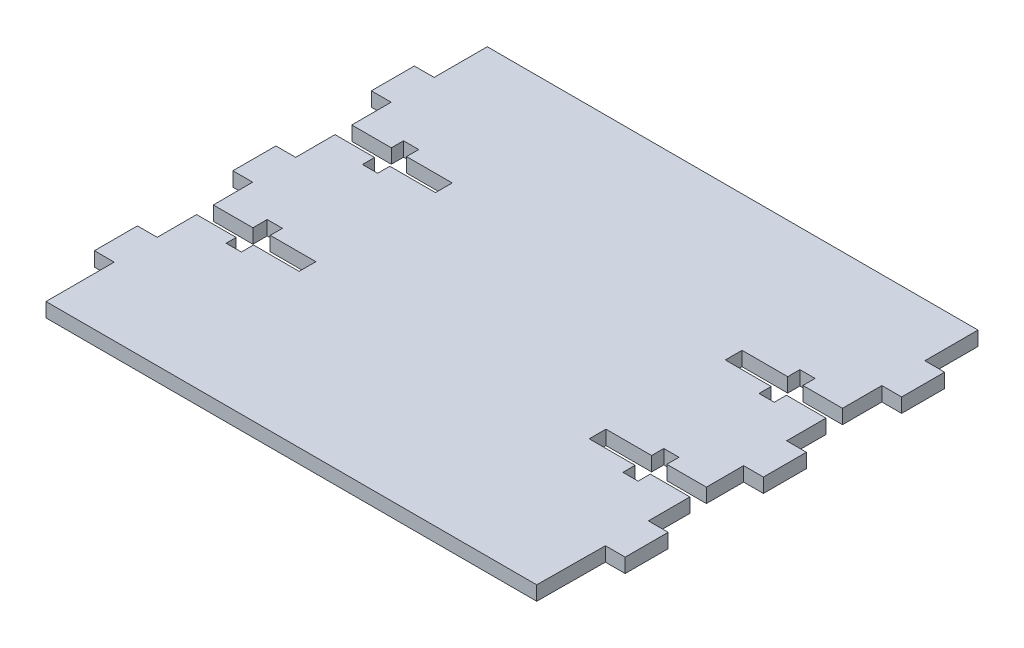
from build123d import *

# Parameters (mm, degrees)
BOSS_EXTRUDE2_DEPTH = 2.38125


with BuildPart() as part:
    # Sketch1 → Boss-Extrude2 (new body)
    with BuildSketch(Plane(origin=(0, 0, 0), x_dir=(1, 0, 0), z_dir=(0, 1, 0))):
        Polygon((0, 73.66), (81.915, 73.66), (81.915, 64.788475447), (85.217, 64.788475447), (85.217, 57.612975447), (81.915, 57.612975447), (81.915, 51.040725447), (75.311, 51.040725447), (75.311, 53.072725447), (72.771, 53.072725447), (72.771, 51.040725447), (65.151, 51.040725447), (65.151, 48.246725447), (72.809250882, 48.246725447), (72.809250882, 46.214725447), (75.349250882, 46.214725447), (75.349250882, 48.246725447), (81.953250882, 48.246725447), (81.953250882, 41.674475447), (85.255250882, 41.674475447), (85.255250882, 34.498975447), (81.953250882, 34.498975447), (81.953250882, 28.281019423), (75.349250882, 28.281019423), (75.349250882, 30.313019423), (72.809250882, 30.313019423), (72.809250882, 28.281019423), (65.189250882, 28.281019423), (65.189250882, 26.884019423), (65.189250882, 25.487019423), (72.847501763, 25.487019423), (72.847501763, 23.455019423), (75.387501763, 23.455019423), (75.387501763, 25.487019423), (81.991501763, 25.487019423), (81.991501763, 18.560475447), (85.293501763, 18.560475447), (85.293501763, 11.384975447), (81.991501763, 11.384975447), (81.915, 0), (0, 0), (0, 11.384975447), (-3.302, 11.384975447), (-3.302, 18.560475447), (0.003462387, 18.560475447), (0.003462387, 25.132725447), (6.610924774, 25.132725447), (6.610924774, 23.455019423), (9.150924774, 23.455019423), (9.150924774, 25.487019423), (16.770924774, 25.487019423), (16.770924774, 28.281019423), (9.150924774, 28.281019423), (9.150924774, 30.313019423), (6.607462387, 30.313019423), (6.607462387, 27.926725447), (0.003462387, 27.926725447), (0.003462387, 34.498975447), (-3.302, 34.498975447), (-3.302, 38.016561862), (-3.302, 41.674475447), (0, 41.674475447), (0, 48.246725447), (6.604, 48.246725447), (6.604, 46.214725447), (9.144, 46.214725447), (9.144, 48.246725447), (16.764, 48.246725447), (16.764, 51.040725447), (9.144, 51.040725447), (9.144, 53.072725447), (6.604, 53.072725447), (6.604, 51.040725447), (0, 51.040725447), (0, 57.612975447), (-3.302, 57.612975447), (-3.302, 64.788475447), (0, 64.788475447), align=None)
    extrude(amount=-BOSS_EXTRUDE2_DEPTH)


solid = part.part
